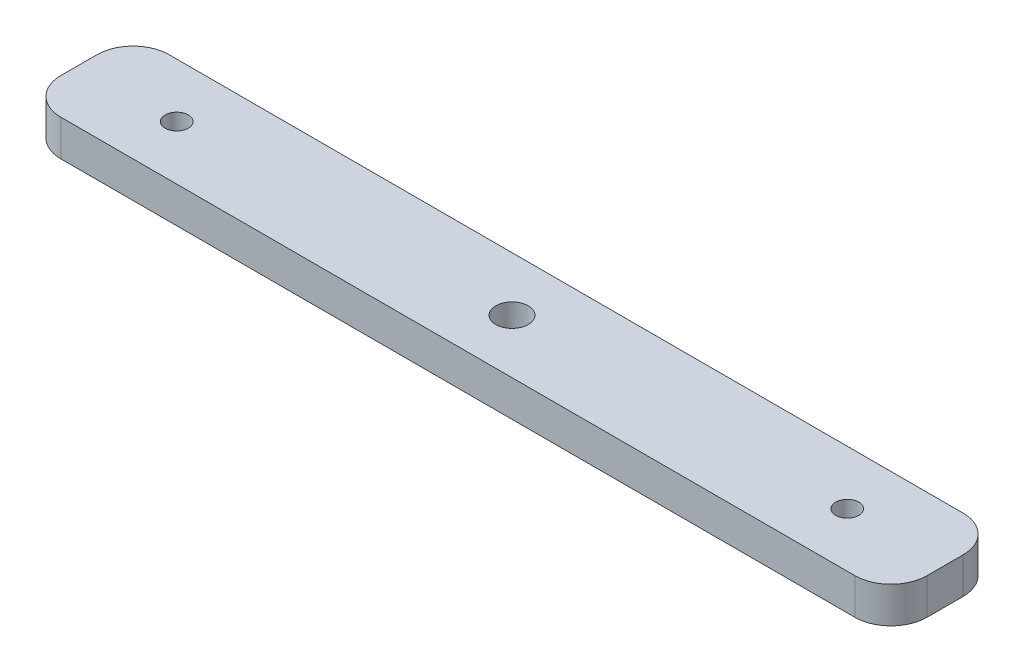
from build123d import *

# Parameters (mm, degrees)
SKETCH_1_W          = 120
SKETCH_1_H          = 15
EXTRUDE_1_DEPTH     = 5
SKETCH_2_R          = 1.6
SKETCH_2_R_2        = 2.25
CUT_EXTRUDE_1_DEPTH = 6
FILLET_1_R          = 5


with BuildPart() as part:
    # Эскиз1 → Бобышка-Вытянуть1 (new body)
    with BuildSketch(Plane(origin=(0, 0, 0), x_dir=(1, 0, 0), z_dir=(0, 1, 0))):
        with Locations((60, 7.5)):
            Rectangle(SKETCH_1_W, SKETCH_1_H)
    extrude(amount=EXTRUDE_1_DEPTH)

    # Эскиз2 → Вырез-Вытянуть1 (cut, through all)
    with BuildSketch(Plane(origin=(0, 5, 0), x_dir=(1, 0, 0), z_dir=(0, 1, 0))):
        with Locations((13.55, 7.5)):
            Circle(SKETCH_2_R)
        with Locations((106.45, 7.5)):
            Circle(SKETCH_2_R)
        with Locations((60, 7.5)):
            Circle(SKETCH_2_R_2)
    extrude(amount=-CUT_EXTRUDE_1_DEPTH, mode=Mode.SUBTRACT)

    # Скругление1
    fillet_1_edges = [part.edges().sort_by_distance(p)[0] for p in [
        (0, 2.5, -15),
        (120, 2.5, -15),
        (120, 2.5, 0),
        (0, 2.5, 0),
    ]]
    fillet(fillet_1_edges, radius=FILLET_1_R)


solid = part.part
